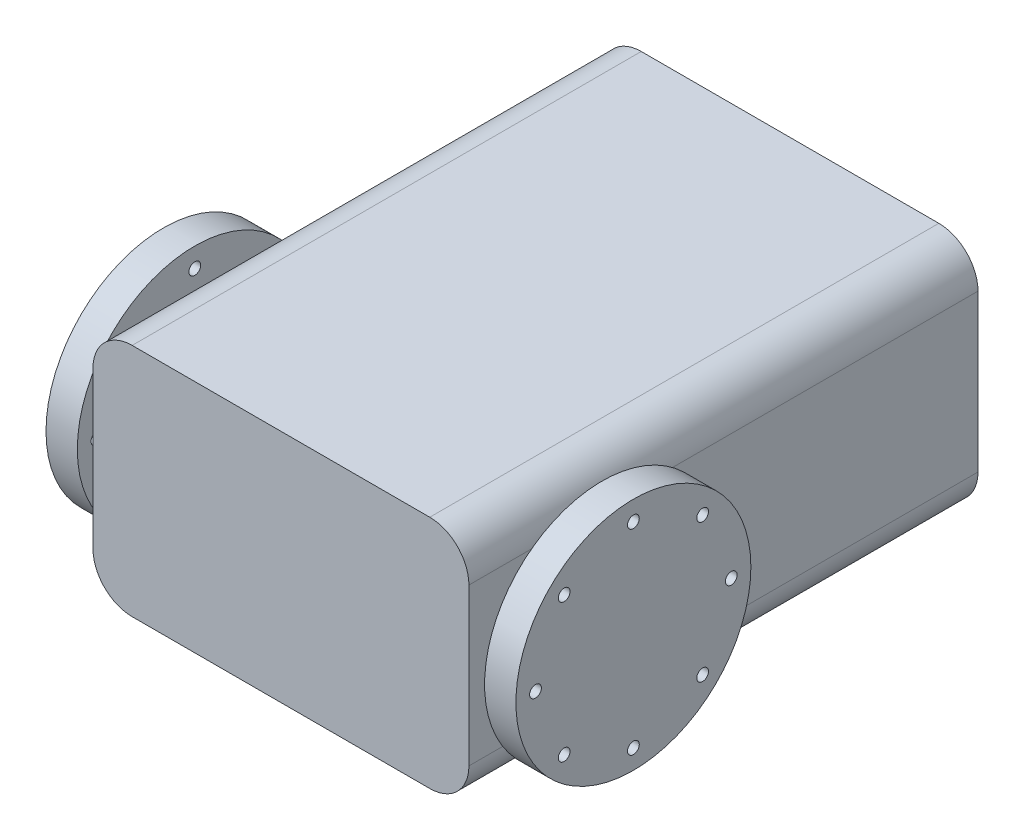
from build123d import *

# Parameters (mm, degrees)
BOSS_EXTRUDE1_DEPTH = 32.5
BOSS_EXTRUDE2_START = 2
SKETCH2_R           = 15
BOSS_EXTRUDE2_DEPTH = 4
SKETCH3_R           = 7.5
BOSS_EXTRUDE3_DEPTH = 50
SKETCH4_R           = 15
BOSS_EXTRUDE4_DEPTH = 4
SKETCH5_R           = 0.75
CUT_EXTRUDE1_DEPTH  = 4
SKETCH6_R           = 0.75
CUT_EXTRUDE2_DEPTH  = 4


with BuildPart() as part:
    # Sketch1 → Boss-Extrude1 (new body, symmetric)
    with BuildSketch(Plane.XY):
        with BuildLine():
            Line((-19, -15), (19, -15))
            ThreePointArc((19, -15), (22.535533906, -13.535533906), (24, -10))
            Line((24, -10), (24, 10))
            ThreePointArc((24, 10), (22.535533906, 13.535533906), (19, 15))
            Line((19, 15), (-19, 15))
            ThreePointArc((-19, 15), (-22.535533906, 13.535533906), (-24, 10))
            Line((-24, 10), (-24, -10))
            ThreePointArc((-24, -10), (-22.535533906, -13.535533906), (-19, -15))
        make_face()
    extrude(amount=BOSS_EXTRUDE1_DEPTH, both=True)



with BuildPart() as body_2:
    # Sketch2 → Boss-Extrude2 (new body)
    with BuildSketch(Plane(origin=(24, 0, 0), x_dir=(0, 0, -1), z_dir=(1, 0, 0)).offset(BOSS_EXTRUDE2_START)):
        with Locations((-17.5, 0)):
            Circle(SKETCH2_R)
    extrude(amount=BOSS_EXTRUDE2_DEPTH)


with BuildPart() as part_1:
    add(part.part)

    add(body_2.part)  # Boss-Extrude3 merges body 2
    # Sketch3 → Boss-Extrude3 (add)
    with BuildSketch(Plane.ZY.offset(-26)):
        with Locations((17.5, 0)):
            Circle(SKETCH3_R)
    boss_extrude3 = extrude(amount=BOSS_EXTRUDE3_DEPTH)

    # Mirror3: Boss-Extrude3 across plane
    add(boss_extrude3.mirror(Plane(origin=(0, 0, 0), x_dir=(0, 0, 1), z_dir=(1, 0, 0))))

    # Sketch4 → Boss-Extrude4 (add)
    with BuildSketch(Plane.ZY.offset(26)):
        with Locations((17.5, 0)):
            Circle(SKETCH4_R)
    extrude(amount=BOSS_EXTRUDE4_DEPTH)

    # Sketch5 → Cut-Extrude1 (cut)
    with BuildSketch(Plane(origin=(30, 0, 0), x_dir=(0, 0, -1), z_dir=(1, 0, 0))):
        with Locations((-17.5, 12.5)):
            Circle(SKETCH5_R)
        with Locations((-8.661165235, 8.838834765)):
            Circle(SKETCH5_R)
        with Locations((-5, 0)):
            Circle(SKETCH5_R)
        with Locations((-8.661165235, -8.838834765)):
            Circle(SKETCH5_R)
        with Locations((-17.5, -12.5)):
            Circle(SKETCH5_R)
        with Locations((-26.338834765, -8.838834765)):
            Circle(SKETCH5_R)
        with Locations((-30, 0)):
            Circle(SKETCH5_R)
        with Locations((-26.338834765, 8.838834765)):
            Circle(SKETCH5_R)
    extrude(amount=-CUT_EXTRUDE1_DEPTH, mode=Mode.SUBTRACT)

    # Sketch6 → Cut-Extrude2 (cut)
    with BuildSketch(Plane.ZY.offset(30)):
        with Locations((17.5, 12.5)):
            Circle(SKETCH6_R)
        with Locations((26.338834765, 8.838834765)):
            Circle(SKETCH6_R)
        with Locations((30, 0)):
            Circle(SKETCH6_R)
        with Locations((26.338834765, -8.838834765)):
            Circle(SKETCH6_R)
        with Locations((17.5, -12.5)):
            Circle(SKETCH6_R)
        with Locations((8.661165235, -8.838834765)):
            Circle(SKETCH6_R)
        with Locations((5, 0)):
            Circle(SKETCH6_R)
        with Locations((8.661165235, 8.838834765)):
            Circle(SKETCH6_R)
    extrude(amount=-CUT_EXTRUDE2_DEPTH, mode=Mode.SUBTRACT)


solid = part_1.part
